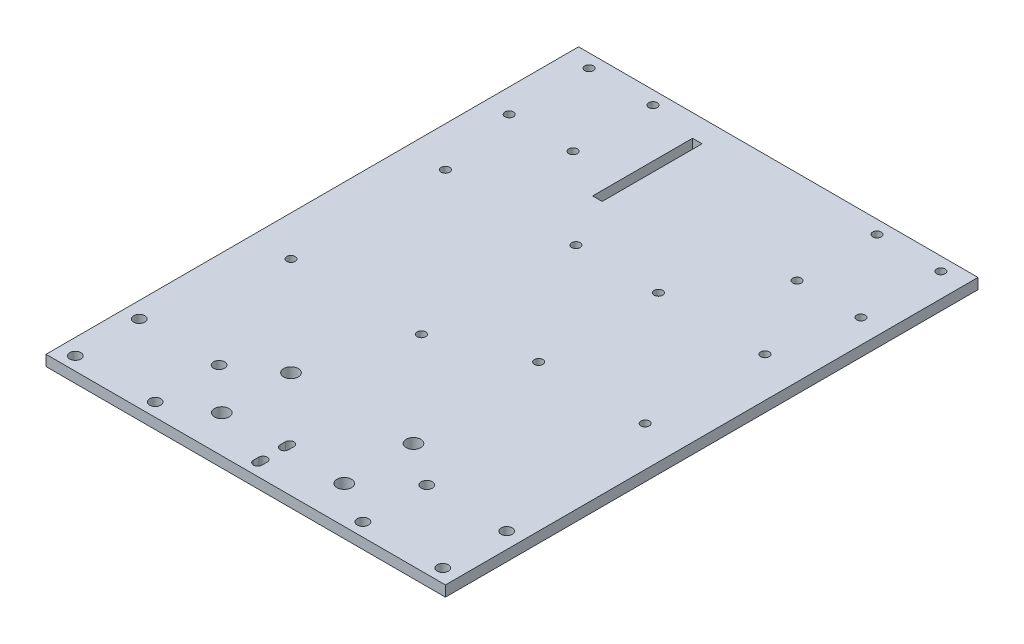
from build123d import *

# Parameters (mm, degrees)
SKETCH_1_W          = 150
SKETCH_1_H          = 200
EXTRUDE_1_DEPTH     = 4
SKETCH_2_R          = 1.6
SKETCH_2_R_2        = 2.75
SKETCH_2_R_3        = 2.1
SKETCH_2_W          = 3.58217065
SKETCH_2_H          = 37.507433864
CUT_EXTRUDE_1_DEPTH = 5


with BuildPart() as part:
    # 草图1 → 凸台-拉伸1 (new body)
    with BuildSketch(Plane(origin=(0, 0, 0), x_dir=(1, 0, 0), z_dir=(0, 1, 0))):
        with Locations((0, -30)):
            Rectangle(SKETCH_1_W, SKETCH_1_H)
    extrude(amount=EXTRUDE_1_DEPTH)

    # 草图2 → 切除-拉伸1 (cut, through all)
    with BuildSketch(Plane(origin=(0, 4, 0), x_dir=(1, 0, 0), z_dir=(0, 1, 0))):
        with Locations((-66.052318668, 65)):
            Circle(SKETCH_2_R)
        with Locations((-66.052318668, 35)):
            Circle(SKETCH_2_R)
        with Locations((-42.052318668, 65)):
            Circle(SKETCH_2_R)
        with Locations((-42.052318668, 35)):
            Circle(SKETCH_2_R)
        with Locations((42.052318668, 35)):
            Circle(SKETCH_2_R)
        with Locations((66.052318668, 35)):
            Circle(SKETCH_2_R)
        with Locations((66.052318668, 65)):
            Circle(SKETCH_2_R)
        with Locations((42.052318668, 65)):
            Circle(SKETCH_2_R)
        with Locations((-23, -90)):
            Circle(SKETCH_2_R_2)
        with Locations((-23, -116)):
            Circle(SKETCH_2_R_2)
        with Locations((-69, -101)):
            Circle(SKETCH_2_R_3)
        with Locations((-69, -125)):
            Circle(SKETCH_2_R_3)
        with Locations((69, -125)):
            Circle(SKETCH_2_R_3)
        with Locations((69, -101)):
            Circle(SKETCH_2_R_3)
        with Locations((23, -116)):
            Circle(SKETCH_2_R_2)
        with Locations((23, -90)):
            Circle(SKETCH_2_R_2)
        with Locations((-39, -125)):
            Circle(SKETCH_2_R_3)
        with Locations((-39, -101)):
            Circle(SKETCH_2_R_3)
        with Locations((39, -125)):
            Circle(SKETCH_2_R_3)
        with Locations((39, -101)):
            Circle(SKETCH_2_R_3)
        with Locations((-60, 5)):
            Circle(SKETCH_2_R)
        with Locations((-60, -53)):
            Circle(SKETCH_2_R)
        with Locations((-11, -53)):
            Circle(SKETCH_2_R)
        with Locations((-11, 5)):
            Circle(SKETCH_2_R)
        with Locations((20, 5)):
            Circle(SKETCH_2_R)
        with Locations((60, 5)):
            Circle(SKETCH_2_R)
        with Locations((20, -40)):
            Circle(SKETCH_2_R)
        with Locations((60, -40)):
            Circle(SKETCH_2_R)
        with BuildLine():
            Line((-1.6, -123.5), (-1.6, -125.5))
            ThreePointArc((-1.6, -125.5), (0, -127.1), (1.6, -125.5))
            Line((1.6, -125.5), (1.6, -123.5))
            ThreePointArc((1.6, -123.5), (0, -121.9), (-1.6, -123.5))
        make_face()
        with BuildLine():
            Line((-1.6, -113.5), (-1.6, -115.5))
            ThreePointArc((-1.6, -115.5), (0, -117.1), (1.6, -115.5))
            Line((1.6, -115.5), (1.6, -113.5))
            ThreePointArc((1.6, -113.5), (0, -111.9), (-1.6, -113.5))
        make_face()
        with Locations((-22.068717893, 42.893406935)):
            Rectangle(SKETCH_2_W, SKETCH_2_H)
    extrude(amount=-CUT_EXTRUDE_1_DEPTH, mode=Mode.SUBTRACT)


solid = part.part
